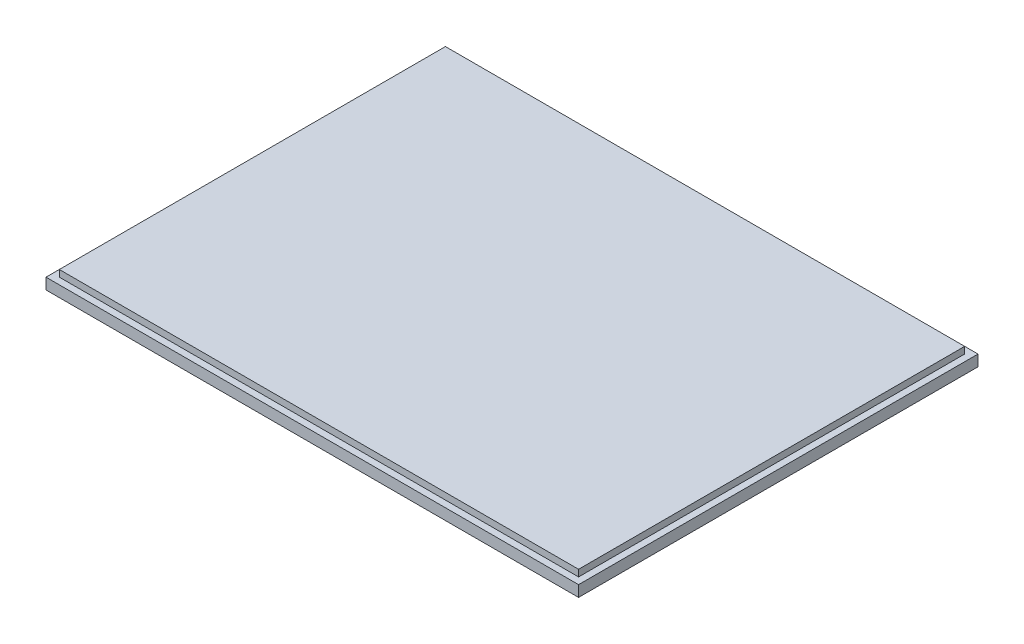
from build123d import *

# Parameters (mm, degrees)
SKETCH1_W           = 120
SKETCH1_H           = 90
BOSS_EXTRUDE1_DEPTH = 4
SKETCH2_OUTSIDE_W   = 152.01
SKETCH2_OUTSIDE_H   = 122.01
SKETCH2_OUTSIDE_W_2 = 117
SKETCH2_OUTSIDE_H_2 = 87
CUT_EXTRUDE1_DEPTH  = 1.5


with BuildPart() as part:
    # Sketch1 → Boss-Extrude1 (new body)
    with BuildSketch(Plane(origin=(0, 0, 0), x_dir=(1, 0, 0), z_dir=(0, 1, 0))):
        Rectangle(SKETCH1_W, SKETCH1_H)
    extrude(amount=BOSS_EXTRUDE1_DEPTH)

    # Sketch2 outside → Cut-Extrude1 (cut)
    with BuildSketch(Plane(origin=(0, 4, 0), x_dir=(1, 0, 0), z_dir=(0, 1, 0))):
        Rectangle(SKETCH2_OUTSIDE_W, SKETCH2_OUTSIDE_H)
        Rectangle(SKETCH2_OUTSIDE_W_2, SKETCH2_OUTSIDE_H_2, mode=Mode.SUBTRACT)
    extrude(amount=-CUT_EXTRUDE1_DEPTH, mode=Mode.SUBTRACT)


solid = part.part
